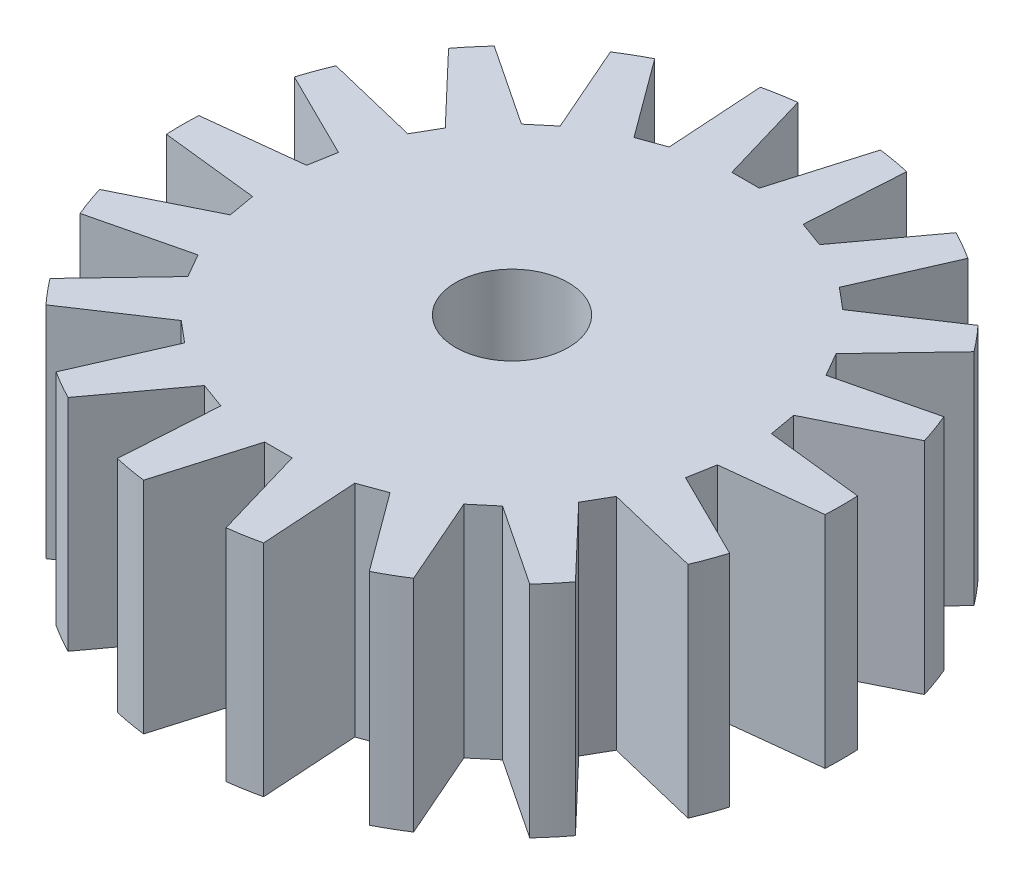
from build123d import *

# Parameters (mm, degrees)
SKETCH1_R           = 12
BOSS_EXTRUDE1_DEPTH = 8
SKETCH2_R           = 2.05
CUT_EXTRUDE1_DEPTH  = 9
CUT_EXTRUDE2_DEPTH  = 9
CIRPATTERN1_COUNT   = 18


with BuildPart() as part:
    # Sketch1 → Boss-Extrude1 (new body)
    with BuildSketch(Plane(origin=(0, 0, 0), x_dir=(1, 0, 0), z_dir=(0, 1, 0))):
        Circle(SKETCH1_R)
    extrude(amount=BOSS_EXTRUDE1_DEPTH)

    # Sketch2 → Cut-Extrude1 (cut, through all)
    with BuildSketch(Plane(origin=(0, 8, 0), x_dir=(1, 0, 0), z_dir=(0, 1, 0))):
        Circle(SKETCH2_R)
    extrude(amount=-CUT_EXTRUDE1_DEPTH, mode=Mode.SUBTRACT)

    # Sketch3 → Cut-Extrude2 (cut, through all)
    with BuildSketch(Plane(origin=(0, 8, 0), x_dir=(1, 0, 0), z_dir=(0, 1, 0))):
        Polygon((0, 8.5), (0.5, 8.5), (1.5, 11.9058809), (1.5, 12.741082781), (-1.5, 12.741082781), (-1.5, 11.9058809), (-0.5, 8.5), align=None)
    cut_extrude2 = extrude(amount=-CUT_EXTRUDE2_DEPTH, mode=Mode.SUBTRACT)

    # CirPattern1: Cut-Extrude2 ×18 about axis
    cirpattern1_axis = Axis((0, 0, 0), (0, 1, 0))
    for i in range(1, CIRPATTERN1_COUNT):
        add(cut_extrude2.rotate(cirpattern1_axis, i * 360 / CIRPATTERN1_COUNT), mode=Mode.SUBTRACT)


solid = part.part
